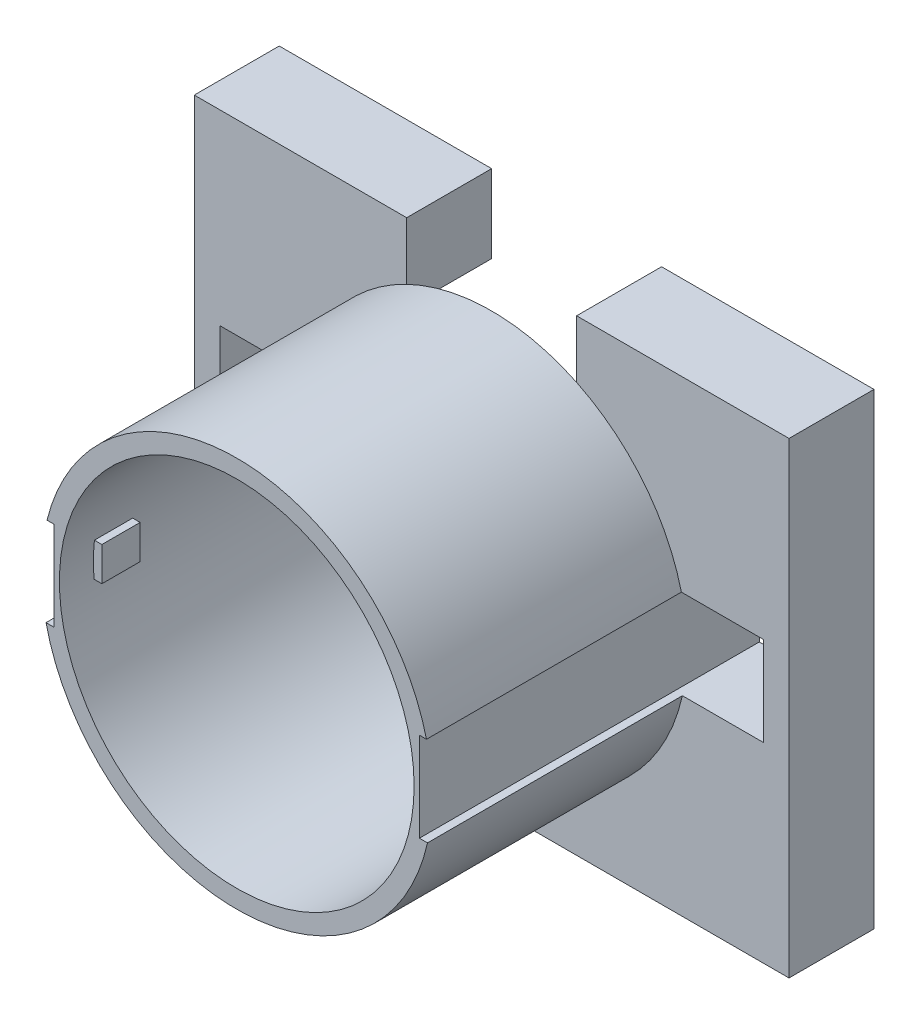
from build123d import *

# Parameters (mm, degrees)
SKETCH_1_W          = 140
SKETCH_1_H          = 110
SKETCH_1_R          = 41.75
EXTRUDE_2_DEPTH     = 20
SKETCH_3_R          = 46
SKETCH_3_R_2        = 41.75
EXTRUDE_3_DEPTH     = 60
SKETCH_4_W          = 21
SKETCH_4_H          = 21
CUT_EXTRUDE_1_DEPTH = 81
SKETCH_6_W          = 9
SKETCH_6_H          = 8
EXTRUDE_4_DEPTH     = 2
SKETCH_7_W          = 9
SKETCH_7_H          = 8
EXTRUDE_5_DEPTH     = 2
CUT_EXTRUDE_2_REACH = 112
SKETCH_8_W          = 40
SKETCH_8_H          = 20


with BuildPart() as part:
    # 草圖1 → 填料-伸長2 (new body)
    with BuildSketch(Plane.XY):
        Rectangle(SKETCH_1_W, SKETCH_1_H)
        Circle(SKETCH_1_R, mode=Mode.SUBTRACT)
    extrude(amount=EXTRUDE_2_DEPTH)

    # 草圖3 → 填料-伸長3 (add)
    with BuildSketch(Plane.XY.offset(20)):
        Circle(SKETCH_3_R)
        Circle(SKETCH_3_R_2, mode=Mode.SUBTRACT)
    extrude(amount=EXTRUDE_3_DEPTH)

    # 草圖4 → 除料-伸長1 (cut, through all)
    with BuildSketch(Plane(origin=(0, 0, 0), x_dir=(-1, 0, 0), z_dir=(0, 0, -1))):
        with Locations((53.5, 0.5)):
            Rectangle(SKETCH_4_W, SKETCH_4_H)
        with Locations((-53.5, 0.5)):
            Rectangle(SKETCH_4_W, SKETCH_4_H)
    extrude(amount=-CUT_EXTRUDE_1_DEPTH, mode=Mode.SUBTRACT)

    # 草圖6 → 填料-伸長4 (add)
    with BuildSketch(Plane(origin=(-41.75, 0, 0), x_dir=(0, 0, -1), z_dir=(1, 0, 0))):
        with Locations((-67.5, 0.5)):
            Rectangle(SKETCH_6_W, SKETCH_6_H)
    extrude(amount=EXTRUDE_4_DEPTH)

    # 草圖7 → 填料-伸長5 (add)
    with BuildSketch(Plane.ZY.offset(-41.75)):
        with Locations((67.5, 0.5)):
            Rectangle(SKETCH_7_W, SKETCH_7_H)
    extrude(amount=EXTRUDE_5_DEPTH)

    # 草圖8 → 除料-伸長2 (cut, up to next)
    with BuildSketch(Plane(origin=(0, 55, 0), x_dir=(1, 0, 0), z_dir=(0, 1, 0)), mode=Mode.PRIVATE) as cut_extrude_2_sk1:
        with Locations((0, -10)):
            Rectangle(SKETCH_8_W, SKETCH_8_H)
    cut_extrude_2_tool1 = extrude(cut_extrude_2_sk1.sketch, amount=-CUT_EXTRUDE_2_REACH, mode=Mode.PRIVATE) & part.part
    add(cut_extrude_2_tool1.solids().sort_by_distance((0, 55, 10))[0], mode=Mode.SUBTRACT)


solid = part.part
